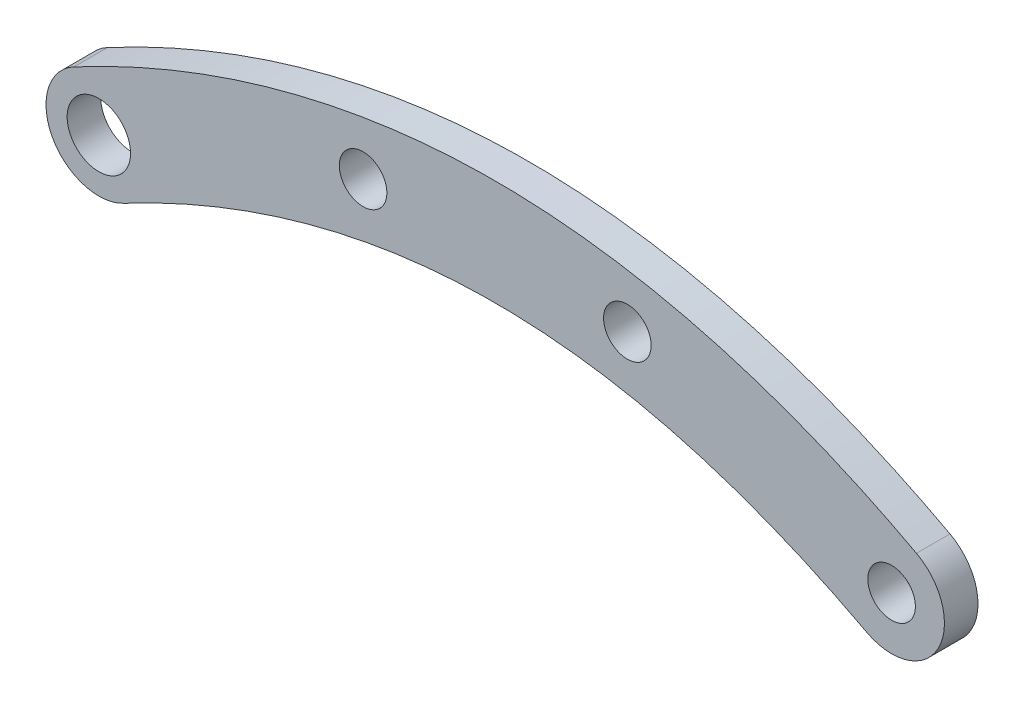
from build123d import *

# Parameters (mm, degrees)
BOSS_EXTRUDE1_DEPTH  = 1.5875
M4_CLEARANCE_HOLE1_D = 4.5
SKETCH5_R            = 3
CUT_EXTRUDE1_DEPTH   = 4.1750001


with BuildPart() as part:
    # Sketch1 → Boss-Extrude1 (new body, symmetric)
    with BuildSketch(Plane.XY):
        with BuildLine():
            ThreePointArc((-35.147058824, -14.411764706), (-41.911764706, -12.352941176), (-39.852941176, -5.588235294))
            add(Edge.make_bspline(
                [(-39.852941176, -5.588235294), (-25.087835375, 2.313761515), (0, 5.671559621), (25.087835375, 2.313761515), (39.852941176, -5.588235294)],
                knots=[0, 0, 0, 0.375, 0.625, 1, 1, 1], degree=2))
            ThreePointArc((39.852941176, -5.588235294), (41.911764706, -12.352941176), (35.147058824, -14.411764706))
            add(Edge.make_bspline(
                [(-35.147058824, -14.411764706), (-21.787164625, -7.313761515), (0, -4.421559621), (21.787164625, -7.313761515), (35.147058824, -14.411764706)],
                knots=[0, 0, 0, 0.375, 0.625, 1, 1, 1], degree=2))
        make_face()
    extrude(amount=BOSS_EXTRUDE1_DEPTH, both=True)

    # M4 Clearance Hole1 (through all)
    with Locations(Plane.XY.offset(1.5875)):
        with Locations((37.5, -10), (-12.5, -1.111111111), (12.5, -1.111111111)):
            Hole(M4_CLEARANCE_HOLE1_D / 2)

    # Sketch5 → Cut-Extrude1 (cut, through all)
    with BuildSketch(Plane.XY.offset(1.5875)):
        with Locations((-37.5, -10)):
            Circle(SKETCH5_R)
    extrude(amount=-CUT_EXTRUDE1_DEPTH, mode=Mode.SUBTRACT)


solid = part.part
